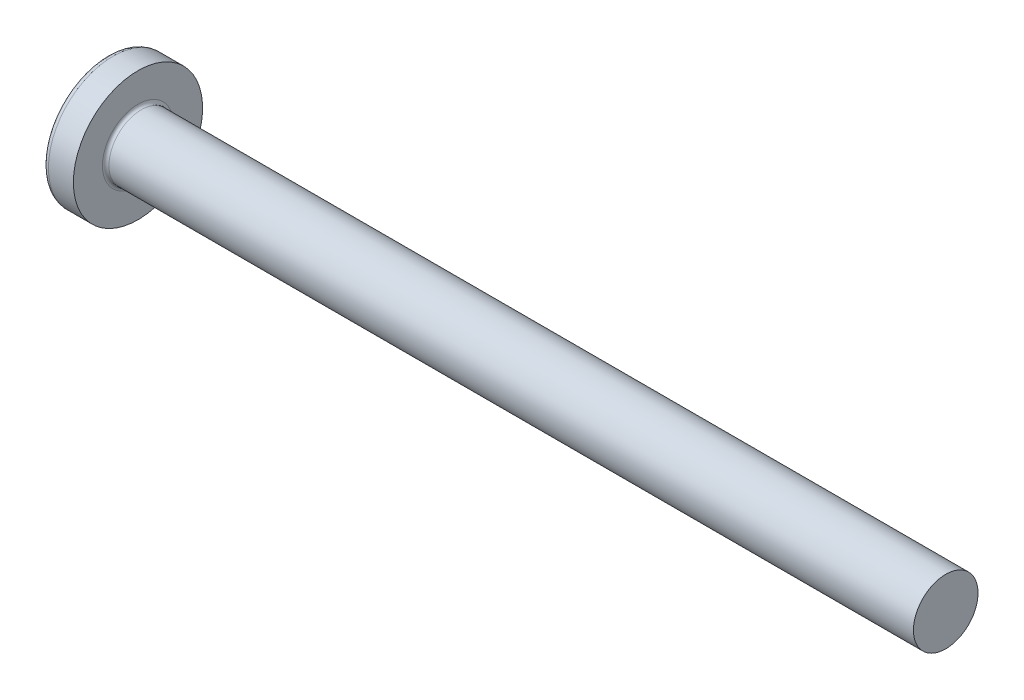
from build123d import *

# Parameters (mm, degrees)
FILLET1_R    = 0.2
SKETCH3_W    = 1.03
SKETCH3_H    = 4.3
SKETCH4_W    = 1.03
SKETCH4_H    = 1.966638154
RECPAT_COUNT = 2
RECPAT_ANGLE = 90


with BuildPart() as part:
    # BodySke → Base-Revolve (revolve)
    with BuildSketch(Plane.XY):
        with BuildLine():
            Line((3.1, 2), (3.1, 4))
            Line((3.1, 4), (1.555305874, 4))
            ThreePointArc((1.555305874, 4), (1.392873227, 3.961271902), (1.265388955, 3.853420195))
            ThreePointArc((1.265388955, 3.853420195), (0.324444487, 2.027933456), (0, 0))
            Line((0, 0), (53.1, 0))
            Line((53.1, 0), (53.1, 2))
            Line((53.1, 2), (3.1, 2))
        make_face()
    revolve(axis=Axis((-25.4, 0, 0), (1, 0, 0)))

    # Fillet1
    fillet1_edges = [part.edges().sort_by_distance(p)[0] for p in [
        (3.1, -2, 0),
    ]]
    fillet(fillet1_edges, radius=FILLET1_R)

    # Sketch3 → Recess section 0
    with BuildSketch(Plane(origin=(0, 0, 0), x_dir=(0, 0, -1), z_dir=(1, 0, 0))):
        Rectangle(SKETCH3_W, SKETCH3_H)
    # Sketch4 → Recess section 1
    with BuildSketch(Plane(origin=(2.34, 0, 0), x_dir=(0, 0, -1), z_dir=(1, 0, 0))):
        Rectangle(SKETCH4_W, SKETCH4_H)
    recess = loft(mode=Mode.SUBTRACT)

    # RecPat: Recess ×2 about axis
    recpat_axis = Axis((0, 0, 0), (1, 0, 0))
    for i in range(1, RECPAT_COUNT):
        add(recess.rotate(recpat_axis, i * RECPAT_ANGLE / (RECPAT_COUNT - 1)), mode=Mode.SUBTRACT)

    # RecCorSke → RecessCore (revolve, cut)
    with BuildSketch(Plane.XY):
        Polygon((0, 0), (0, 1.01462874), (2.34, 0.851), (2.616506661, 0), align=None)
    revolve(axis=Axis((-3.175, 0, 0), (1, 0, 0)), mode=Mode.SUBTRACT)


solid = part.part
